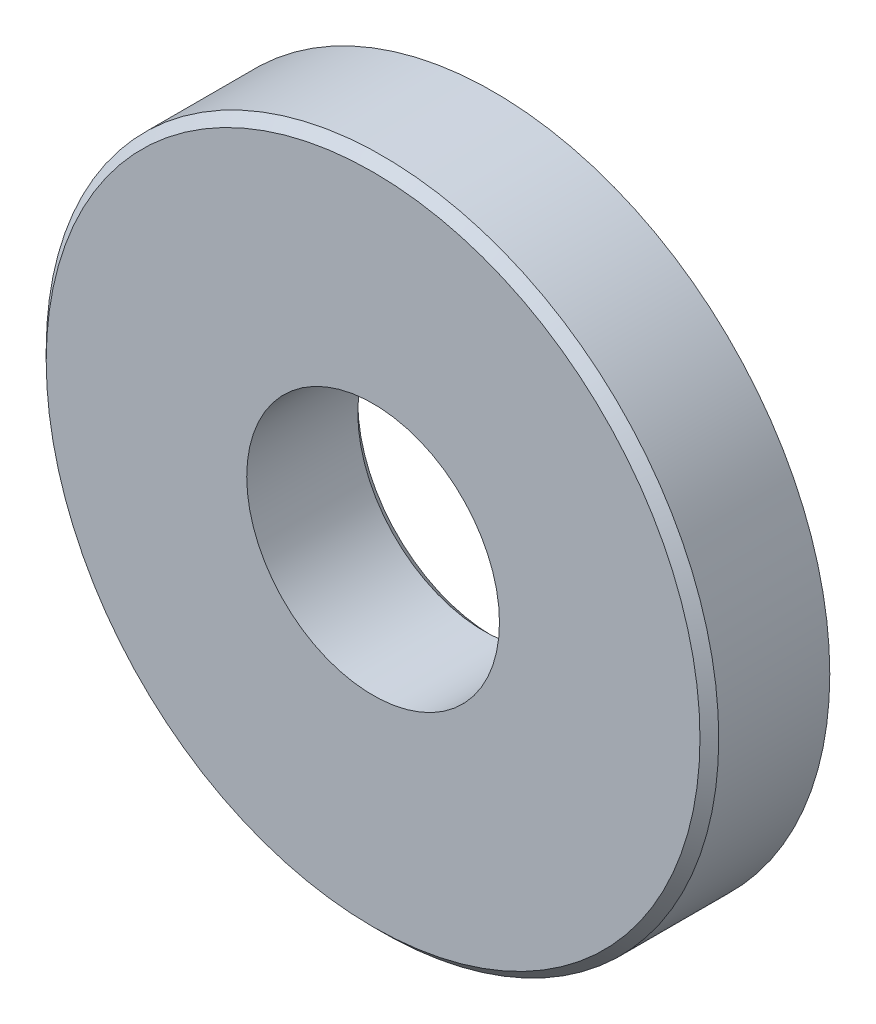
from build123d import *

# Parameters (mm, degrees)
SKETCH_1_R      = 10.75
SKETCH_1_R_2    = 4.04
EXTRUDE_1_DEPTH = 3.85
CHAMFER_1_SIZE  = 0.3
CHAMFER_2_SIZE  = 0.3


with BuildPart() as part:
    # 草图1 → 凸台-拉伸1 (new body)
    with BuildSketch(Plane.XY):
        Circle(SKETCH_1_R)
        Circle(SKETCH_1_R_2, mode=Mode.SUBTRACT)
    extrude(amount=EXTRUDE_1_DEPTH)

    # 倒角1
    chamfer_1_edges = [part.edges().sort_by_distance(p)[0] for p in [
        (-10.75, 0, 3.85),
    ]]
    chamfer(chamfer_1_edges, length=CHAMFER_1_SIZE)

    # 倒角2
    chamfer_2_edges = [part.edges().sort_by_distance(p)[0] for p in [
        (-4.04, 0, 0),
    ]]
    chamfer(chamfer_2_edges, length=CHAMFER_2_SIZE)


solid = part.part
